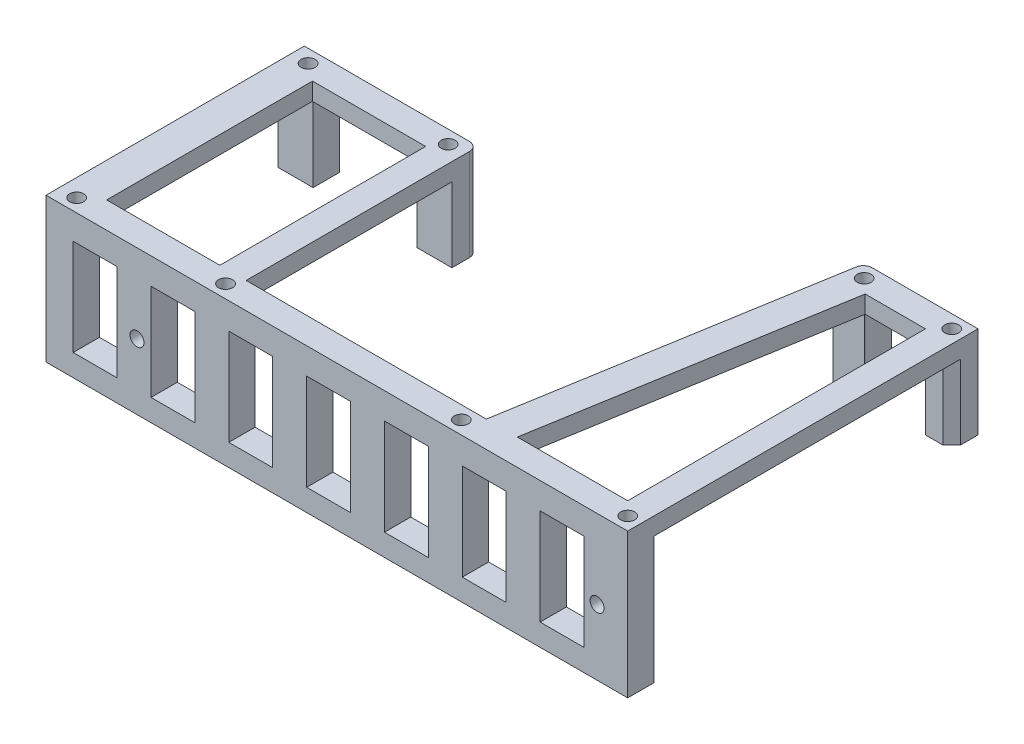
from build123d import *

# Parameters (mm, degrees)
SKETCH_1_R          = 1.6
SKETCH_1_W          = 25.85
SKETCH_1_H          = 47
EXTRUDE_1_DEPTH     = 4
SKETCH_2_W          = 8
SKETCH_2_H          = 6
SKETCH_2_R          = 1.6
EXTRUDE_2_DEPTH     = 17
FILLET_1_R          = 2
SKETCH_3_W          = 132.85
SKETCH_3_H          = 6
EXTRUDE_3_DEPTH     = 29
SKETCH_4_W          = 10
SKETCH_4_H          = 22
CUT_EXTRUDE_1_DEPTH = 7
SKETCH_5_R          = 1.6
CUT_EXTRUDE_2_DEPTH = 34
SKETCH_6_R          = 1.6
CUT_EXTRUDE_3_DEPTH = 7


with BuildPart() as part:
    # Эскиз1 → Бобышка-Вытянуть1 (new body)
    with BuildSketch(Plane(origin=(0, 0, 0), x_dir=(1, 0, 0), z_dir=(0, 1, 0))):
        Polygon((66, 24), (66, -56), (-66.85, -56), (-66.85, 3), (-59.15, 3), (-34.85, 3), (-27.15, 3), (-27.15, -50), (27.704212942, -50), (40.133263836, 24), (60, 24), align=None)
        with Locations((63, 21)):
            Circle(SKETCH_1_R, mode=Mode.SUBTRACT)
        with Locations((-63, 0)):
            Circle(SKETCH_1_R, mode=Mode.SUBTRACT)
        with Locations((-31, 0)):
            Circle(SKETCH_1_R, mode=Mode.SUBTRACT)
        with Locations((43, 21)):
            Circle(SKETCH_1_R, mode=Mode.SUBTRACT)
        with Locations((-46.075, -26.5)):
            Rectangle(SKETCH_1_W, SKETCH_1_H, mode=Mode.SUBTRACT)
        Polygon((60, 18), (60, -50), (34.802263374, -50), (46.223553385, 18), align=None, mode=Mode.SUBTRACT)
    extrude(amount=EXTRUDE_1_DEPTH)

    # Эскиз2 → Бобышка-Вытянуть2 (add)
    with BuildSketch(Plane.XZ):
        with Locations((-62.85, 0)):
            Rectangle(SKETCH_2_W, SKETCH_2_H)
        with Locations((-63, 0)):
            Circle(SKETCH_2_R, mode=Mode.SUBTRACT)
        Polygon((66, -20), (66, -24), (60, -24), (60, -18), (64, -18), align=None)
        with Locations((63, -21)):
            Circle(SKETCH_2_R, mode=Mode.SUBTRACT)
        with Locations((-31.15, 0)):
            Rectangle(SKETCH_2_W, SKETCH_2_H)
        with Locations((-31, 0)):
            Circle(SKETCH_2_R, mode=Mode.SUBTRACT)
        Polygon((46.223553385, -18), (46.223553385, -24), (40.133263836, -24), (39.097062378, -17.830670696), (46.195112811, -17.830670696), align=None)
        with Locations((43, -21)):
            Circle(SKETCH_2_R, mode=Mode.SUBTRACT)
    extrude(amount=EXTRUDE_2_DEPTH)

    # Скругление1
    fillet_1_edges = [part.edges().sort_by_distance(p)[0] for p in [
        (-27.15, -6.5, -3),
        (40.133263836, -6.5, -24),
    ]]
    fillet(fillet_1_edges, radius=FILLET_1_R)

    # Эскиз3 → Бобышка-Вытянуть3 (add)
    with BuildSketch(Plane.XZ):
        with Locations((-0.425, 53)):
            Rectangle(SKETCH_3_W, SKETCH_3_H)
    extrude(amount=EXTRUDE_3_DEPTH)

    # Эскиз4 → Вырез-Вытянуть1 (cut, through all)
    with BuildSketch(Plane(origin=(0, 0, 50), x_dir=(-1, 0, 0), z_dir=(0, 0, -1))):
        with Locations((20.095331259, -13)):
            Rectangle(SKETCH_4_W, SKETCH_4_H)
        with Locations((2.321498445, -13)):
            Rectangle(SKETCH_4_W, SKETCH_4_H)
        with Locations((-15.45233437, -13)):
            Rectangle(SKETCH_4_W, SKETCH_4_H)
        with Locations((-33.226167185, -13)):
            Rectangle(SKETCH_4_W, SKETCH_4_H)
        with Locations((-51, -13)):
            Rectangle(SKETCH_4_W, SKETCH_4_H)
        with Locations((37.869164074, -13)):
            Rectangle(SKETCH_4_W, SKETCH_4_H)
        with Locations((55.642996889, -13)):
            Rectangle(SKETCH_4_W, SKETCH_4_H)
    extrude(amount=-CUT_EXTRUDE_1_DEPTH, mode=Mode.SUBTRACT)

    # Эскиз5 → Вырез-Вытянуть2 (cut, through all)
    with BuildSketch(Plane(origin=(0, 4, 0), x_dir=(1, 0, 0), z_dir=(0, 1, 0))):
        with Locations((-62.85, -53)):
            Circle(SKETCH_5_R)
        with Locations((-28.85, -53)):
            Circle(SKETCH_5_R)
        with Locations((63, -53)):
            Circle(SKETCH_5_R)
        with Locations((25, -53)):
            Circle(SKETCH_5_R)
    extrude(amount=-CUT_EXTRUDE_2_DEPTH, mode=Mode.SUBTRACT)

    # Эскиз6 → Вырез-Вытянуть3 (cut, through all)
    with BuildSketch(Plane(origin=(0, 0, 50), x_dir=(-1, 0, 0), z_dir=(0, 0, -1))):
        with Locations((46.075, -14)):
            Circle(SKETCH_6_R)
        with Locations((-59, -14)):
            Circle(SKETCH_6_R)
    extrude(amount=-CUT_EXTRUDE_3_DEPTH, mode=Mode.SUBTRACT)


solid = part.part
